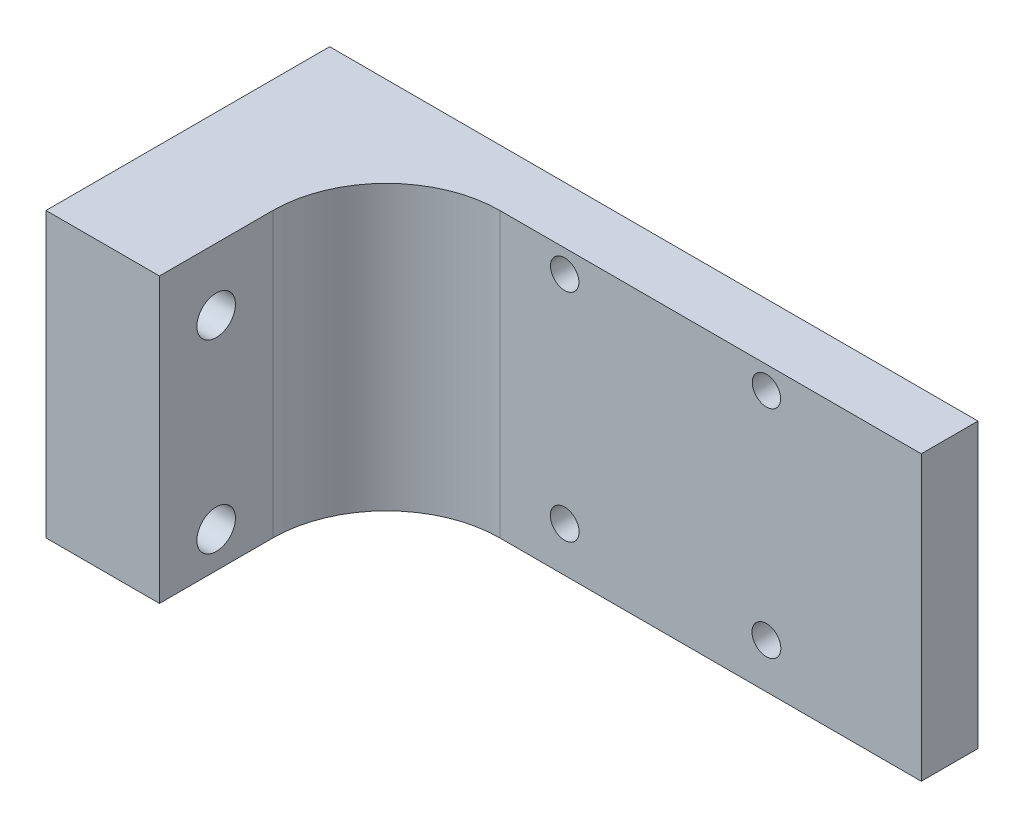
from build123d import *

# Parameters (mm, degrees)
SKETCH1_W           = 57.15
SKETCH1_H           = 25
BOSS_EXTRUDE1_DEPTH = 5
SKETCH2_R           = 1.25
SKETCH2_R_2         = 1.27
CUT_EXTRUDE2_DEPTH  = 6
SKETCH5_W           = 10
SKETCH5_H           = 25
BOSS_EXTRUDE3_DEPTH = 20
FILLET1_R           = 10
SKETCH6_R           = 1.7
CUT_EXTRUDE3_DEPTH  = 11


with BuildPart() as part:
    # Sketch1 → Boss-Extrude1 (new body)
    with BuildSketch(Plane.XY):
        with Locations((28.575, -12.5)):
            Rectangle(SKETCH1_W, SKETCH1_H)
    extrude(amount=BOSS_EXTRUDE1_DEPTH)

    # Sketch2 → Cut-Extrude2 (cut, through all)
    with BuildSketch(Plane.XY.offset(5)):
        with Locations((25.72, -2)):
            Circle(SKETCH2_R)
        with Locations((43.5, -2)):
            Circle(SKETCH2_R)
        with Locations((25.72, -21.05)):
            Circle(SKETCH2_R_2)
        with Locations((43.5, -21.05)):
            Circle(SKETCH2_R_2)
    extrude(amount=-CUT_EXTRUDE2_DEPTH, mode=Mode.SUBTRACT)

    # Sketch5 → Boss-Extrude3 (add)
    with BuildSketch(Plane.XY.offset(5)):
        with Locations((5, -12.5)):
            Rectangle(SKETCH5_W, SKETCH5_H)
    extrude(amount=BOSS_EXTRUDE3_DEPTH)

    # Fillet1
    fillet1_edges = [part.edges().sort_by_distance(p)[0] for p in [
        (10, -12.5, 5),
    ]]
    fillet(fillet1_edges, radius=FILLET1_R)

    # Sketch6 → Cut-Extrude3 (cut, through all)
    with BuildSketch(Plane(origin=(10, 0, 0), x_dir=(0, 0, -1), z_dir=(1, 0, 0))):
        with Locations((-20, -21.834919238)):
            Circle(SKETCH6_R)
        with Locations((-20, -5.503108416)):
            Circle(SKETCH6_R)
    extrude(amount=-CUT_EXTRUDE3_DEPTH, mode=Mode.SUBTRACT)


solid = part.part
